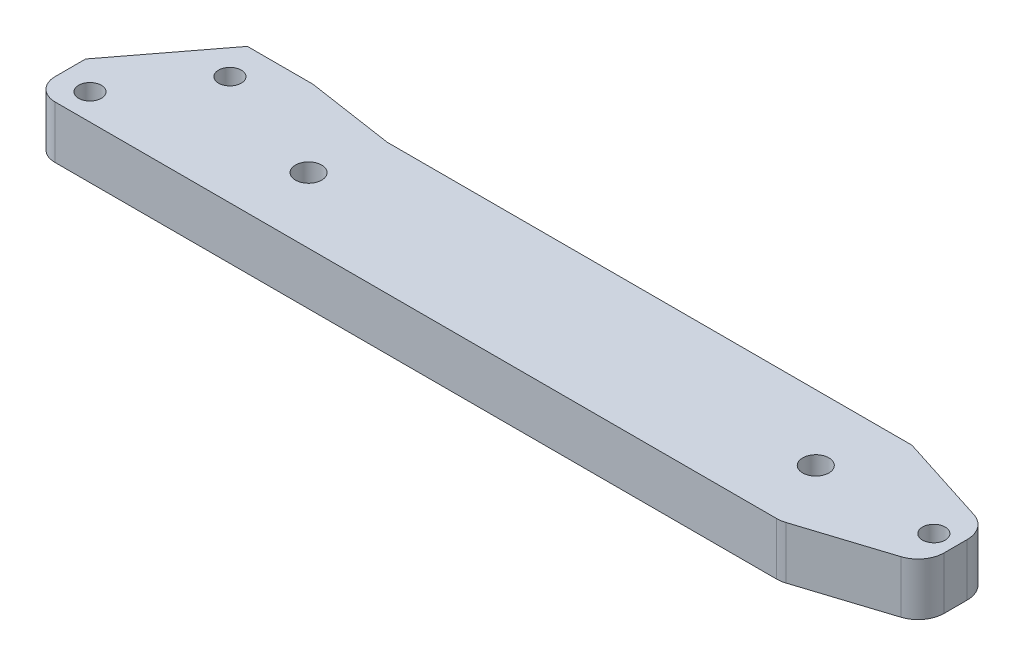
from build123d import *

# Parameters (mm, degrees)
SKETCH1_R           = 2.6
SKETCH1_R_2         = 3
BOSS_EXTRUDE1_DEPTH = 12
FILLET1_R           = 5
FILLET2_R           = 6


with BuildPart() as part:
    # Sketch1 → Boss-Extrude1 (new body)
    with BuildSketch(Plane(origin=(0, 0, 0), x_dir=(1, 0, 0), z_dir=(0, 1, 0))):
        Polygon((180, 22), (155, 30), (35, 30), (15, 33), (0, 33), (-16, 12), (-16, 0), (0, 0), (155, 0), (180, 8), align=None)
        with Locations((-9, 6)):
            Circle(SKETCH1_R, mode=Mode.SUBTRACT)
        with Locations((148, 15)):
            Circle(SKETCH1_R_2, mode=Mode.SUBTRACT)
        with Locations((32, 15)):
            Circle(SKETCH1_R_2, mode=Mode.SUBTRACT)
        with Locations((175, 15)):
            Circle(SKETCH1_R, mode=Mode.SUBTRACT)
        with Locations((4, 25)):
            Circle(SKETCH1_R, mode=Mode.SUBTRACT)
    extrude(amount=BOSS_EXTRUDE1_DEPTH)

    # Fillet1
    fillet1_edges = [part.edges().sort_by_distance(p)[0] for p in [
        (-16, 6, 0),
    ]]
    fillet(fillet1_edges, radius=FILLET1_R)

    # Fillet2
    fillet2_edges = [part.edges().sort_by_distance(p)[0] for p in [
        (180, 6, -22),
        (180, 6, -8),
        (155, 6, 0),
    ]]
    fillet(fillet2_edges, radius=FILLET2_R)


solid = part.part
